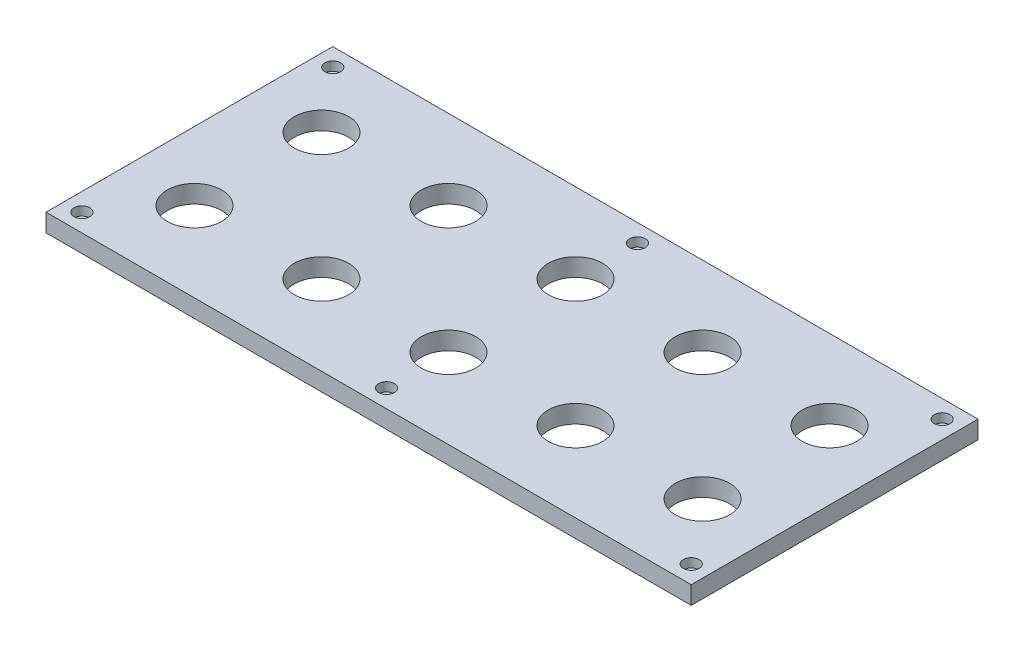
from build123d import *

# Parameters (mm, degrees)
SKETCH1_W                                        = 457.2
SKETCH1_H                                        = 203.2
BOSS_EXTRUDE1_DEPTH                              = 12.7
CUT_EXTRUDE1_REACH                               = 14.7
SKETCH2_R                                        = 19.304
CBORE_FOR_1_4_SOCKET_HEAD_CAP_SCREW1_D           = 6.7564
CBORE_FOR_1_4_SOCKET_HEAD_CAP_SCREW1_DEPTH       = 12.7
CBORE_FOR_1_4_SOCKET_HEAD_CAP_SCREW1_CBORE_D     = 11.1125
CBORE_FOR_1_4_SOCKET_HEAD_CAP_SCREW1_CBORE_DEPTH = 6.35


with BuildPart() as part:
    # Sketch1 → Boss-Extrude1 (new body)
    with BuildSketch(Plane(origin=(0, 0, 0), x_dir=(1, 0, 0), z_dir=(0, 1, 0))):
        Rectangle(SKETCH1_W, SKETCH1_H)
    extrude(amount=-BOSS_EXTRUDE1_DEPTH)

    # Sketch2 → Cut-Extrude1 (cut, up to next)
    with BuildSketch(Plane(origin=(0, 0, 0), x_dir=(1, 0, 0), z_dir=(0, 1, 0)), mode=Mode.PRIVATE) as cut_extrude1_sk1:
        with Locations((-180, 45)):
            Circle(SKETCH2_R)
    cut_extrude1_tool1 = extrude(cut_extrude1_sk1.sketch, amount=-CUT_EXTRUDE1_REACH, mode=Mode.PRIVATE) & part.part
    add(cut_extrude1_tool1.solids().sort_by_distance((-180, 0, -45))[0], mode=Mode.SUBTRACT)
    # Sketch2 → Cut-Extrude1 (cut, up to next)
    with BuildSketch(Plane(origin=(0, 0, 0), x_dir=(1, 0, 0), z_dir=(0, 1, 0)), mode=Mode.PRIVATE) as cut_extrude1_sk2:
        with Locations((-90, 45)):
            Circle(SKETCH2_R)
    cut_extrude1_tool2 = extrude(cut_extrude1_sk2.sketch, amount=-CUT_EXTRUDE1_REACH, mode=Mode.PRIVATE) & part.part
    add(cut_extrude1_tool2.solids().sort_by_distance((-90, 0, -45))[0], mode=Mode.SUBTRACT)
    # Sketch2 → Cut-Extrude1 (cut, up to next)
    with BuildSketch(Plane(origin=(0, 0, 0), x_dir=(1, 0, 0), z_dir=(0, 1, 0)), mode=Mode.PRIVATE) as cut_extrude1_sk3:
        with Locations((0, 45)):
            Circle(SKETCH2_R)
    cut_extrude1_tool3 = extrude(cut_extrude1_sk3.sketch, amount=-CUT_EXTRUDE1_REACH, mode=Mode.PRIVATE) & part.part
    add(cut_extrude1_tool3.solids().sort_by_distance((0, 0, -45))[0], mode=Mode.SUBTRACT)
    # Sketch2 → Cut-Extrude1 (cut, up to next)
    with BuildSketch(Plane(origin=(0, 0, 0), x_dir=(1, 0, 0), z_dir=(0, 1, 0)), mode=Mode.PRIVATE) as cut_extrude1_sk4:
        with Locations((-180, -45)):
            Circle(SKETCH2_R)
    cut_extrude1_tool4 = extrude(cut_extrude1_sk4.sketch, amount=-CUT_EXTRUDE1_REACH, mode=Mode.PRIVATE) & part.part
    add(cut_extrude1_tool4.solids().sort_by_distance((-180, 0, 45))[0], mode=Mode.SUBTRACT)
    # Sketch2 → Cut-Extrude1 (cut, up to next)
    with BuildSketch(Plane(origin=(0, 0, 0), x_dir=(1, 0, 0), z_dir=(0, 1, 0)), mode=Mode.PRIVATE) as cut_extrude1_sk5:
        with Locations((-90, -45)):
            Circle(SKETCH2_R)
    cut_extrude1_tool5 = extrude(cut_extrude1_sk5.sketch, amount=-CUT_EXTRUDE1_REACH, mode=Mode.PRIVATE) & part.part
    add(cut_extrude1_tool5.solids().sort_by_distance((-90, 0, 45))[0], mode=Mode.SUBTRACT)
    # Sketch2 → Cut-Extrude1 (cut, up to next)
    with BuildSketch(Plane(origin=(0, 0, 0), x_dir=(1, 0, 0), z_dir=(0, 1, 0)), mode=Mode.PRIVATE) as cut_extrude1_sk6:
        with Locations((0, -45)):
            Circle(SKETCH2_R)
    cut_extrude1_tool6 = extrude(cut_extrude1_sk6.sketch, amount=-CUT_EXTRUDE1_REACH, mode=Mode.PRIVATE) & part.part
    add(cut_extrude1_tool6.solids().sort_by_distance((0, 0, 45))[0], mode=Mode.SUBTRACT)
    # Sketch2 → Cut-Extrude1 (cut, up to next)
    with BuildSketch(Plane(origin=(0, 0, 0), x_dir=(1, 0, 0), z_dir=(0, 1, 0)), mode=Mode.PRIVATE) as cut_extrude1_sk7:
        with Locations((90, -45)):
            Circle(SKETCH2_R)
    cut_extrude1_tool7 = extrude(cut_extrude1_sk7.sketch, amount=-CUT_EXTRUDE1_REACH, mode=Mode.PRIVATE) & part.part
    add(cut_extrude1_tool7.solids().sort_by_distance((90, 0, 45))[0], mode=Mode.SUBTRACT)
    # Sketch2 → Cut-Extrude1 (cut, up to next)
    with BuildSketch(Plane(origin=(0, 0, 0), x_dir=(1, 0, 0), z_dir=(0, 1, 0)), mode=Mode.PRIVATE) as cut_extrude1_sk8:
        with Locations((90, 45)):
            Circle(SKETCH2_R)
    cut_extrude1_tool8 = extrude(cut_extrude1_sk8.sketch, amount=-CUT_EXTRUDE1_REACH, mode=Mode.PRIVATE) & part.part
    add(cut_extrude1_tool8.solids().sort_by_distance((90, 0, -45))[0], mode=Mode.SUBTRACT)
    # Sketch2 → Cut-Extrude1 (cut, up to next)
    with BuildSketch(Plane(origin=(0, 0, 0), x_dir=(1, 0, 0), z_dir=(0, 1, 0)), mode=Mode.PRIVATE) as cut_extrude1_sk9:
        with Locations((180, 45)):
            Circle(SKETCH2_R)
    cut_extrude1_tool9 = extrude(cut_extrude1_sk9.sketch, amount=-CUT_EXTRUDE1_REACH, mode=Mode.PRIVATE) & part.part
    add(cut_extrude1_tool9.solids().sort_by_distance((180, 0, -45))[0], mode=Mode.SUBTRACT)
    # Sketch2 → Cut-Extrude1 (cut, up to next)
    with BuildSketch(Plane(origin=(0, 0, 0), x_dir=(1, 0, 0), z_dir=(0, 1, 0)), mode=Mode.PRIVATE) as cut_extrude1_sk10:
        with Locations((180, -45)):
            Circle(SKETCH2_R)
    cut_extrude1_tool10 = extrude(cut_extrude1_sk10.sketch, amount=-CUT_EXTRUDE1_REACH, mode=Mode.PRIVATE) & part.part
    add(cut_extrude1_tool10.solids().sort_by_distance((180, 0, 45))[0], mode=Mode.SUBTRACT)

    # CBORE for 1/4 Socket Head Cap Screw1
    with Locations(Plane(origin=(0, 0, 0), x_dir=(1, 0, 0), z_dir=(0, 1, 0))):
        with Locations((-215.9, -88.9), (0, -88.9), (215.9, -88.9), (215.9, 88.9), (0, 88.9), (-215.9, 88.9)):
            CounterBoreHole(CBORE_FOR_1_4_SOCKET_HEAD_CAP_SCREW1_D / 2, CBORE_FOR_1_4_SOCKET_HEAD_CAP_SCREW1_CBORE_D / 2, CBORE_FOR_1_4_SOCKET_HEAD_CAP_SCREW1_CBORE_DEPTH, depth=CBORE_FOR_1_4_SOCKET_HEAD_CAP_SCREW1_DEPTH)


solid = part.part
